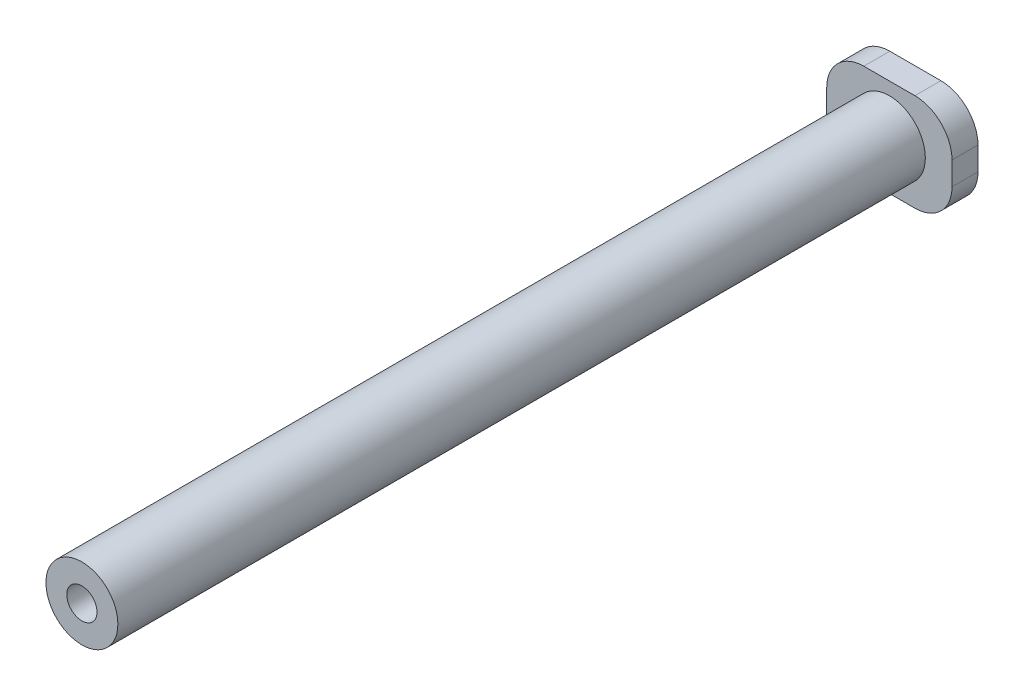
from build123d import *

# Parameters (mm, degrees)
SKETCH4_W           = 13.5
SKETCH4_H           = 10.5
BOSS_EXTRUDE2_DEPTH = 2.8
SKETCH5_R           = 3.875
BOSS_EXTRUDE3_DEPTH = 87
SKETCH6_R           = 1.63
CUT_EXTRUDE1_DEPTH  = 90.8
FILLET1_R           = 4


with BuildPart() as part:
    # Sketch4 → Boss-Extrude2 (new body)
    with BuildSketch(Plane.XY):
        with Locations((6.75, 5.25)):
            Rectangle(SKETCH4_W, SKETCH4_H)
    extrude(amount=BOSS_EXTRUDE2_DEPTH)

    # Sketch5 → Boss-Extrude3 (add)
    with BuildSketch(Plane.XY.offset(2.8)):
        with Locations((6.75, 5.25)):
            Circle(SKETCH5_R)
    extrude(amount=BOSS_EXTRUDE3_DEPTH)

    # Sketch6 → Cut-Extrude1 (cut, through all)
    with BuildSketch(Plane.XY.offset(89.8)):
        with Locations((6.75, 5.25)):
            Circle(SKETCH6_R)
    extrude(amount=-CUT_EXTRUDE1_DEPTH, mode=Mode.SUBTRACT)

    # Fillet1
    fillet1_edges = [part.edges().sort_by_distance(p)[0] for p in [
        (0, 10.5, 1.4),
        (13.5, 10.5, 1.4),
        (13.5, 0, 1.4),
        (0, 0, 1.4),
    ]]
    fillet(fillet1_edges, radius=FILLET1_R)


solid = part.part
